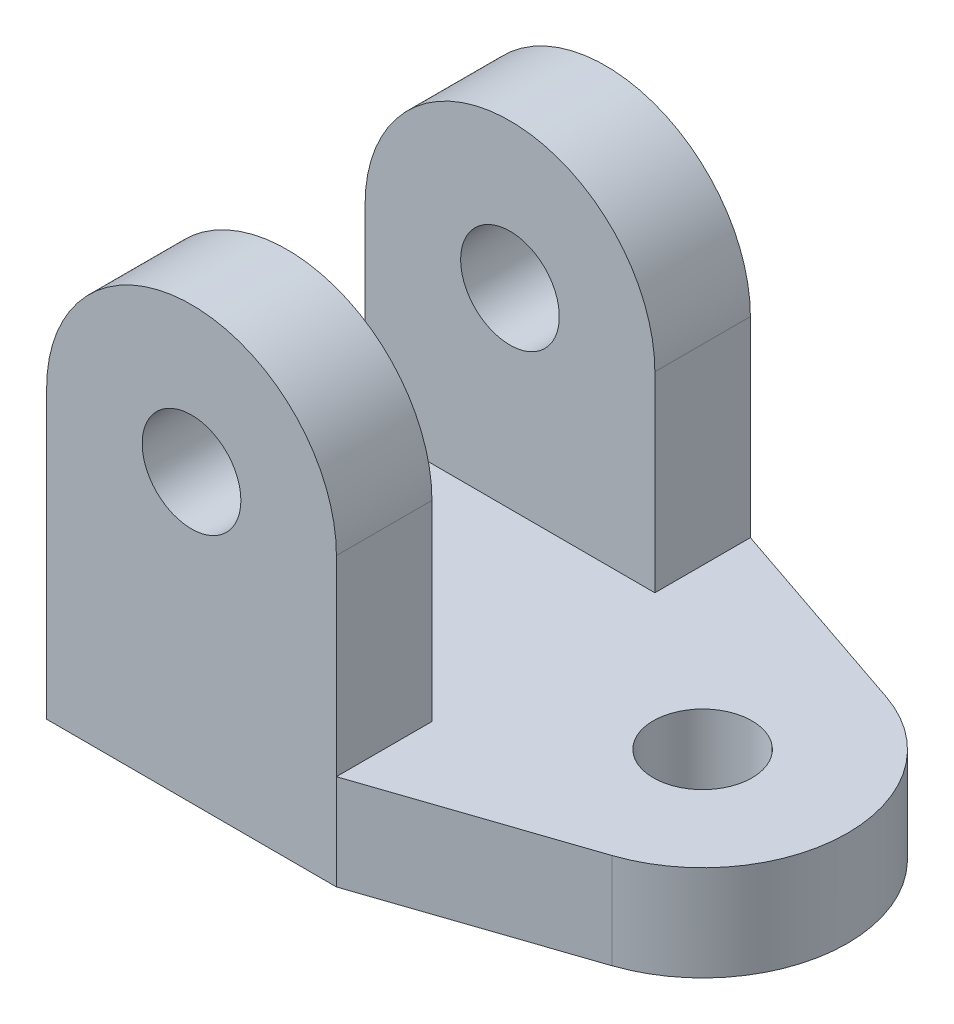
from build123d import *

# Parameters (mm, degrees)
SKETCH1_R           = 1.55
BOSS_EXTRUDE1_DEPTH = 3
SKETCH2_R           = 1.55
BOSS_EXTRUDE2_DEPTH = 3
SKETCH3_R           = 1.55
BOSS_EXTRUDE3_DEPTH = 3


with BuildPart() as part:
    # Sketch1 → Boss-Extrude1 (new body)
    with BuildSketch(Plane.XY):
        with BuildLine():
            ThreePointArc((89.55, -5), (85, -0.45), (80.45, -5))
            Line((80.45, -5), (80.45, -11))
            Line((80.45, -11), (89.55, -11.011788251))
            Line((89.55, -11.011788251), (89.55, -5))
        make_face()
        with Locations((85, -5)):
            Circle(SKETCH1_R, mode=Mode.SUBTRACT)
    extrude(amount=BOSS_EXTRUDE1_DEPTH)



with BuildPart() as body_2:
    # Sketch2 → Boss-Extrude2 (new body)
    with BuildSketch(Plane(origin=(0, 0, -7), x_dir=(-1, 0, 0), z_dir=(0, 0, -1))):
        with BuildLine():
            Line((-89.55, -11.011788251), (-80.45, -11))
            Line((-80.45, -11), (-80.45, -5))
            ThreePointArc((-80.45, -5), (-85, -0.45), (-89.55, -5))
            Line((-89.55, -5), (-89.55, -11.011788251))
        make_face()
        with Locations((-85, -5)):
            Circle(SKETCH2_R, mode=Mode.SUBTRACT)
    extrude(amount=BOSS_EXTRUDE2_DEPTH)


with BuildPart() as part_1:
    add(part.part)

    add(body_2.part)  # Boss-Extrude3 merges body 2
    # Sketch3 → Boss-Extrude3 (add)
    with BuildSketch(Plane(origin=(-0.014114508, -10.895765801, 0), x_dir=(0.999999161, -0.001295411, 0), z_dir=(-0.001295411, -0.999999161, 0))):
        with BuildLine():
            Line((89.564189657, 3), (80.464182022, 3))
            Line((80.464182022, 3), (80.464182022, -10))
            Line((80.464182022, -10), (89.564189657, -10))
            Line((89.564189657, -10), (96.025380607, -7.808993039))
            ThreePointArc((96.025380607, -7.808993039), (99.114189657, -3.5), (96.025380607, 0.808993039))
            Line((96.025380607, 0.808993039), (89.564189657, 3))
        make_face()
        with Locations((94.564189657, -3.5)):
            Circle(SKETCH3_R, mode=Mode.SUBTRACT)
    extrude(amount=BOSS_EXTRUDE3_DEPTH)


solid = part_1.part
